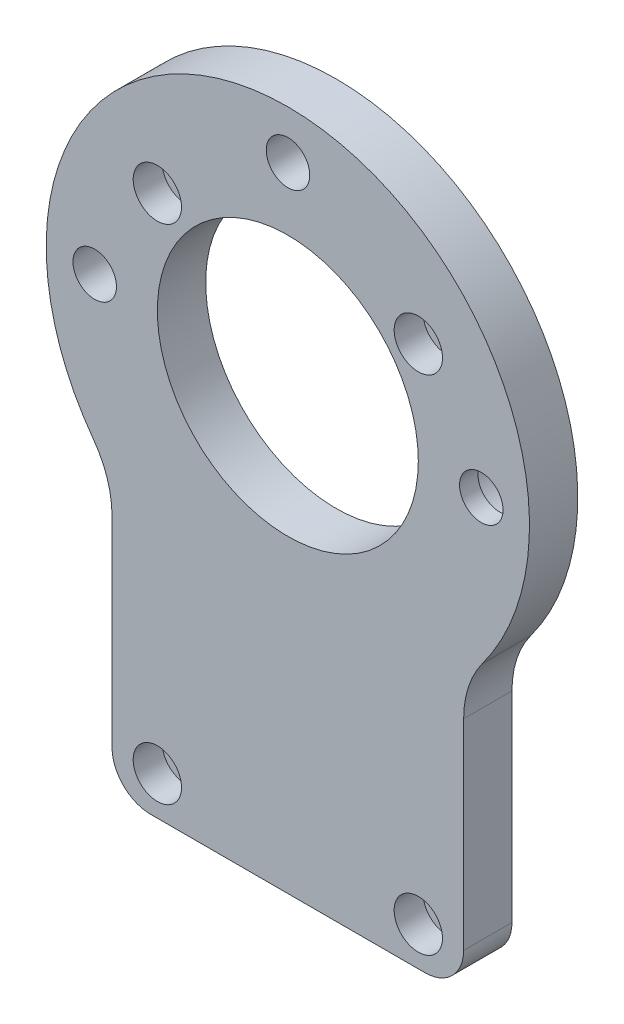
from build123d import *

# Parameters (mm, degrees)
SKETCH_1_R                   = 1.2
SKETCH_1_R_2                 = 13.5
EXTRUDE_1_DEPTH              = 5
SKETCH_2_R                   = 2.5
CUT_EXTRUDE_1_DEPTH          = 3
SKETCH_3_R                   = 2.25
CUT_EXTRUDE_2_DEPTH          = 1
CUT_EXTRUDE_2_DEPTH_BACK     = 6
HOLE_WIZARD_M4_2_D           = 4.5
HOLE_WIZARD_M4_2_CBORE_D     = 9
HOLE_WIZARD_M4_2_CBORE_DEPTH = 3.1


with BuildPart() as part:
    # 스케치1 → 보스-돌출1 (new body)
    with BuildSketch(Plane.XY):
        with BuildLine():
            Line((18.188636287, -5.246102869), (18.188636287, -26))
            ThreePointArc((18.188636287, -26), (17.017063412, -28.828427125), (14.188636287, -30))
            Line((14.188636287, -30), (-14.188636287, -30))
            ThreePointArc((-14.188636287, -30), (-17.017063412, -28.828427125), (-18.188636287, -26))
            Line((-18.188636287, -26), (-18.188636287, -5.246102869))
            ThreePointArc((-18.188636287, -5.246102869), (-18.687611058, -2.126724792), (-20.134740205, 0.681355093))
            ThreePointArc((-20.134740205, 0.681355093), (0, 40.5), (20.134740205, 0.681355093))
            ThreePointArc((20.134740205, 0.681355093), (18.687611058, -2.126724792), (18.188636287, -5.246102869))
        make_face()
        with Locations((-13.5, 26)):
            Circle(SKETCH_1_R, mode=Mode.SUBTRACT)
        with Locations((13.5, 26)):
            Circle(SKETCH_1_R, mode=Mode.SUBTRACT)
        with Locations((-13.5, -26)):
            Circle(SKETCH_1_R, mode=Mode.SUBTRACT)
        with Locations((13.5, -26)):
            Circle(SKETCH_1_R, mode=Mode.SUBTRACT)
        with Locations((0, 15.5)):
            Circle(SKETCH_1_R_2, mode=Mode.SUBTRACT)
    extrude(amount=EXTRUDE_1_DEPTH)

    # 스케치2 → 컷-돌출1 (cut)
    with BuildSketch(Plane.XY.offset(5)):
        with Locations((-13.5, 26)):
            Circle(SKETCH_2_R)
        with Locations((13.5, 26)):
            Circle(SKETCH_2_R)
        with Locations((-13.5, -26)):
            Circle(SKETCH_2_R)
        with Locations((13.5, -26)):
            Circle(SKETCH_2_R)
    extrude(amount=-CUT_EXTRUDE_1_DEPTH, mode=Mode.SUBTRACT)

    # 스케치3 → 컷-돌출2 (cut, two sides)
    with BuildSketch(Plane.XY.offset(5)) as cut_extrude_2_sk:
        with Locations((-19.982848321, 15.5)):
            Circle(SKETCH_3_R)
        with Locations((0.017151679, 35.5)):
            Circle(SKETCH_3_R)
    extrude(amount=CUT_EXTRUDE_2_DEPTH, mode=Mode.SUBTRACT)
    extrude(cut_extrude_2_sk.sketch, amount=-CUT_EXTRUDE_2_DEPTH_BACK, mode=Mode.SUBTRACT)

    # M4 남비 머리 나사용 카운터보어2 (through all)
    with Locations(Plane(origin=(0, 0, 0), x_dir=(-1, 0, 0), z_dir=(0, 0, -1))):
        with Locations((-20.017151679, 15.5)):
            CounterBoreHole(HOLE_WIZARD_M4_2_D / 2, HOLE_WIZARD_M4_2_CBORE_D / 2, HOLE_WIZARD_M4_2_CBORE_DEPTH)


solid = part.part
